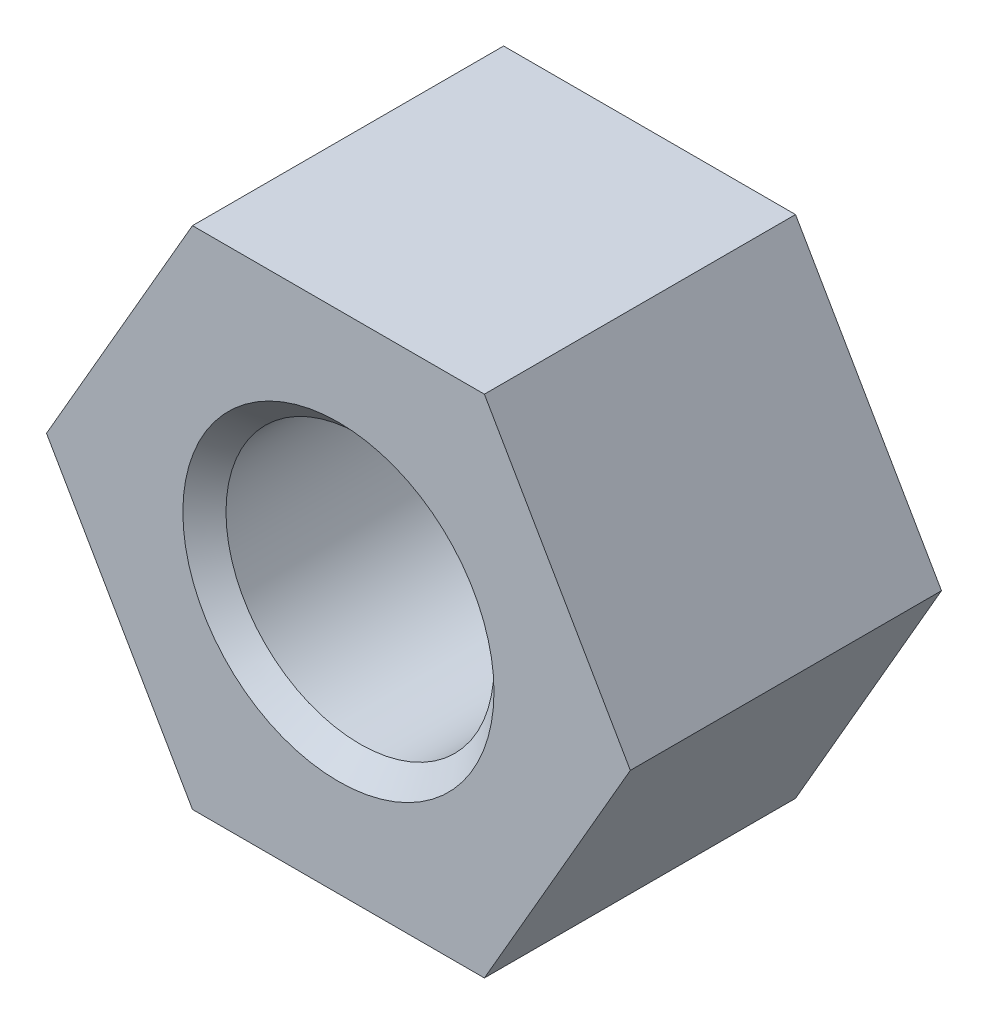
from build123d import *

# Parameters (mm, degrees)
SKETCH_1_R      = 3.4455
EXTRUDE_1_DEPTH = 8
CHAMFER_1_SIZE  = 0.5545


with BuildPart() as part:
    # Эскиз1 → Бобышка-Вытянуть1 (new body)
    with BuildSketch(Plane.XY):
        Polygon((3.75277675, 6.5), (-3.75277675, 6.5), (-7.505553499, 0), (-3.75277675, -6.5), (3.75277675, -6.5), (7.505553499, 0), align=None)
        Circle(SKETCH_1_R, mode=Mode.SUBTRACT)
    extrude(amount=EXTRUDE_1_DEPTH)

    # Фаска1
    chamfer_1_edges = [part.edges().sort_by_distance(p)[0] for p in [
        (-3.4455, 0, 0),
        (-3.4455, 0, 8),
    ]]
    chamfer(chamfer_1_edges, length=CHAMFER_1_SIZE)


solid = part.part
